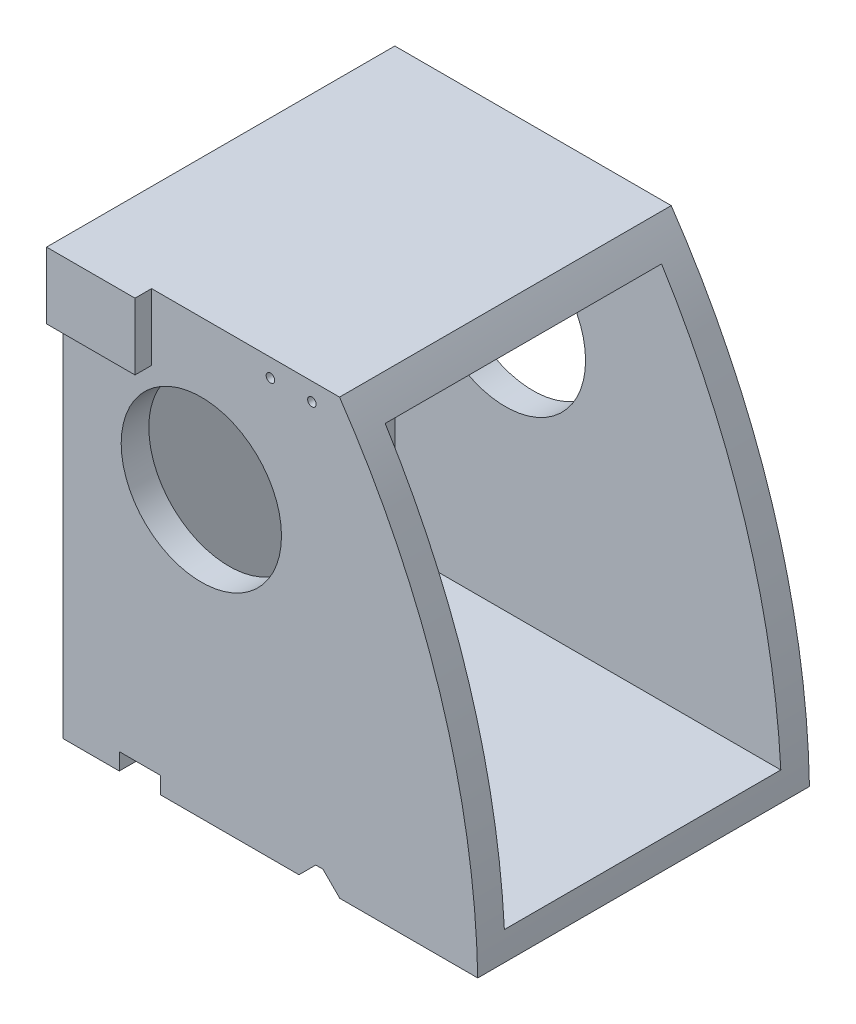
from build123d import *

# Parameters (mm, degrees)
BOSS_EXTRUDE1_DEPTH = 120
SHELL1_T            = -10
SKETCH2_R           = 29
SKETCH2_R_2         = 1.54318701
CUT_EXTRUDE1_DEPTH  = 200
SKETCH3_W           = 15
SKETCH3_H           = 6.085201518
CUT_EXTRUDE2_DEPTH  = 200
SKETCH4_W           = 32
SKETCH4_H           = 24.066005235
BOSS_EXTRUDE2_DEPTH = 6


with BuildPart() as part:
    # Sketch1 → Boss-Extrude1 (new body)
    with BuildSketch(Plane.XY):
        with BuildLine():
            Line((-10.096774194, 144.410679099), (89.903225806, 144.410679099))
            ThreePointArc((89.903225806, 144.410679099), (126.330854691, 69.550051356), (139.903225806, -12.589320901))
            Line((139.903225806, -12.589320901), (-10.096774194, -12.589320901))
            Line((-10.096774194, -12.589320901), (-10.096774194, 144.410679099))
        make_face()
    extrude(amount=BOSS_EXTRUDE1_DEPTH)

    # Shell1
    shell1_openings = [part.faces().sort_by_distance(p)[0] for p in [
        (120.617040249, 67.730365228, 60),
    ]]
    offset(amount=SHELL1_T, openings=shell1_openings, kind=Kind.INTERSECTION)

    # Sketch2 → Cut-Extrude1 (cut)
    with BuildSketch(Plane.XY.offset(120)):
        with Locations((39.903225806, 90.410679099)):
            Circle(SKETCH2_R)
        with Locations((79.903225806, 137.910679099)):
            Circle(SKETCH2_R_2)
        with Locations((64.903225806, 137.910679099)):
            Circle(SKETCH2_R_2)
    extrude(amount=-CUT_EXTRUDE1_DEPTH, mode=Mode.SUBTRACT)

    # Sketch3 → Cut-Extrude2 (cut)
    with BuildSketch(Plane.XY.offset(120)):
        Polygon((75.215541826, -12.589320901), (81.300743344, -6.504119383), (83.903225806, -6.504119383), (89.988427324, -12.589320901), align=None)
        with Locations((17.715541826, -9.546720142)):
            Rectangle(SKETCH3_W, SKETCH3_H)
    extrude(amount=-CUT_EXTRUDE2_DEPTH, mode=Mode.SUBTRACT)

    # Sketch4 → Boss-Extrude2 (add)
    with BuildSketch(Plane.XY.offset(120)):
        with Locations((5.903225806, 132.377676482)):
            Rectangle(SKETCH4_W, SKETCH4_H)
    extrude(amount=BOSS_EXTRUDE2_DEPTH)


solid = part.part
